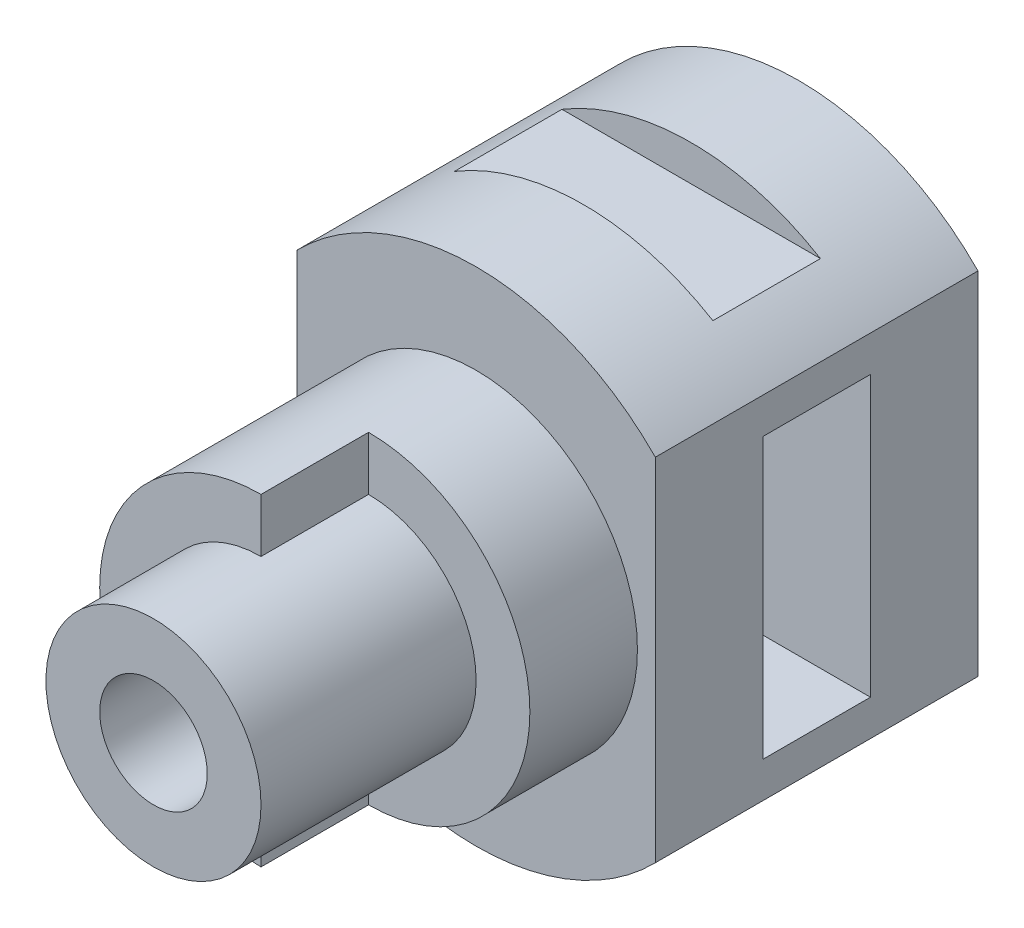
from build123d import *

# Parameters (mm, degrees)
BOSS_EXTRUDE1_DEPTH       = 9
SKETCH2_W                 = 3
SKETCH2_H                 = 1
SKETCH2_H_2               = 7.797958972
CUT_EXTRUDE1_DEPTH        = 19
SKETCH3_R                 = 4.5
BOSS_EXTRUDE2_DEPTH       = 6
SKETCH4_R                 = 3
BOSS_EXTRUDE3_DEPTH       = 3
F_3_0MM_DOWEL_HOLE1_D     = 3
F_3_0MM_DOWEL_HOLE1_DEPTH = 4
F_3_0MM_DOWEL_HOLE1_TIP   = 0.901290929
CUT_EXTRUDE2_DEPTH        = 3


with BuildPart() as part:
    # Sketch1 → Boss-Extrude1 (new body)
    with BuildSketch(Plane.XY):
        with BuildLine():
            ThreePointArc((-5, -4.898979486), (0, -7), (5, -4.898979486))
            Line((5, -4.898979486), (5, 4.898979486))
            ThreePointArc((5, 4.898979486), (0, 7), (-5, 4.898979486))
            Line((-5, 4.898979486), (-5, -4.898979486))
        make_face()
    extrude(amount=BOSS_EXTRUDE1_DEPTH)

    # Sketch2 → Cut-Extrude1 (cut)
    with BuildSketch(Plane.ZY.offset(5)):
        with Locations((4.5, 6.5)):
            Rectangle(SKETCH2_W, SKETCH2_H)
        with Locations((4.5, 0)):
            Rectangle(SKETCH2_W, SKETCH2_H_2)
        Polygon((3, -7), (3.352176654, -7), (6, -7), (6, -6), (3, -6), align=None)
    extrude(amount=-CUT_EXTRUDE1_DEPTH, mode=Mode.SUBTRACT)

    # Sketch3 → Boss-Extrude2 (add)
    with BuildSketch(Plane.XY.offset(9)):
        Circle(SKETCH3_R)
    extrude(amount=BOSS_EXTRUDE2_DEPTH)

    # Sketch4 → Boss-Extrude3 (add)
    with BuildSketch(Plane.XY.offset(15)):
        Circle(SKETCH4_R)
    extrude(amount=BOSS_EXTRUDE3_DEPTH)

    # Ø3.0mm Dowel Hole1
    with Locations(Plane.XY.offset(18)):
        with Locations((0, 0)):
            Hole(F_3_0MM_DOWEL_HOLE1_D / 2, depth=F_3_0MM_DOWEL_HOLE1_DEPTH)
            with Locations((0, 0, -(F_3_0MM_DOWEL_HOLE1_DEPTH + F_3_0MM_DOWEL_HOLE1_TIP / 2))):  # 118° drill point
                Cone(0, F_3_0MM_DOWEL_HOLE1_D / 2, F_3_0MM_DOWEL_HOLE1_TIP, mode=Mode.SUBTRACT)

    # Sketch9 → Cut-Extrude2 (cut)
    with BuildSketch(Plane.XY.offset(15)):
        with BuildLine():
            Line((0, 4.5), (0, 3))
            ThreePointArc((0, 3), (3, 0), (0, -3))
            Line((0, -3), (0, -4.5))
            ThreePointArc((0, -4.5), (4.5, 0), (0, 4.5))
        make_face()
    extrude(amount=-CUT_EXTRUDE2_DEPTH, mode=Mode.SUBTRACT)


solid = part.part
